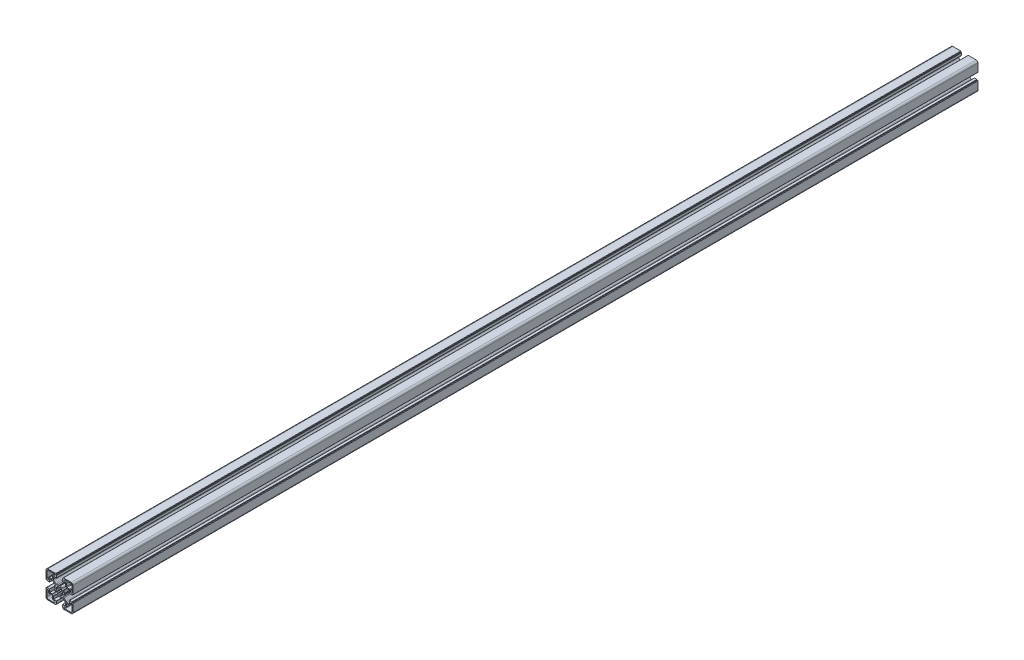
from build123d import *

# Parameters (mm, degrees)
BASE_EXTRUDE_DEPTH = 1510


with BuildPart() as part:
    # Sketch1 → Base-Extrude (new body)
    with BuildSketch(Plane.XY):
        with BuildLine():
            Line((7.973976585, 0.792591518), (7.540060475, 0.046829556))
            ThreePointArc((7.540060475, 0.046829556), (7.534295984, 0.023675638), (7.531329941, 0))
            ThreePointArc((7.531329941, 0), (7.534295984, -0.023675638), (7.540060475, -0.046829556))
            Line((7.540060475, -0.046829556), (7.973976585, -0.792591518))
            ThreePointArc((7.973976585, -0.792591518), (7.996666421, -0.851255641), (8.000014047, -0.914065683))
            ThreePointArc((8.000014047, -0.914065683), (7.719730741, -2.298395946), (7.20036345, -3.611859543))
            ThreePointArc((7.20036345, -3.611859543), (7.018857217, -4.793954471), (7.563483933, -5.85869607))
            Line((7.563483933, -5.85869607), (11.129779889, -9.424988026))
            ThreePointArc((11.129779889, -9.424988026), (11.760624613, -9.84650461), (12.504756513, -9.99452154))
            Line((12.504756513, -9.99452154), (16.316902451, -9.99452154))
            ThreePointArc((16.316902451, -9.99452154), (16.458324055, -9.935942793), (16.516902802, -9.794521189))
            Line((16.516902802, -9.794521189), (16.516902802, -5.200014226))
            ThreePointArc((16.516902802, -5.200014226), (16.575481548, -5.058592621), (16.716903152, -5.000013875))
            Line((16.716903152, -5.000013875), (20.719599904, -5.000013875))
            ThreePointArc((20.719599904, -5.000013875), (20.931731427, -5.087881629), (21.01959918, -5.300013151))
            Line((21.01959918, -5.300013151), (21.01959918, -5.500004099))
            ThreePointArc((21.01959918, -5.500004099), (21.10746708, -5.712135974), (21.319598956, -5.800003874))
            Line((21.319598956, -5.800003874), (21.999979514, -5.800003874))
            ThreePointArc((21.999979514, -5.800003874), (22.35353264, -5.946450374), (22.49997914, -6.300003501))
            Line((22.49997914, -6.300003501), (22.49997914, -19.500016116))
            ThreePointArc((22.49997914, -19.500016116), (21.62130014, -21.621334875), (19.499981381, -22.500013875))
            Line((19.499981381, -22.500013875), (6.375709012, -22.500013875))
            ThreePointArc((6.375709012, -22.500013875), (6.022155886, -22.353567375), (5.875709386, -22.000014249))
            Line((5.875709386, -22.000014249), (5.875709386, -21.30001315))
            ThreePointArc((5.875709386, -21.30001315), (5.787841632, -21.087881628), (5.57571011, -21.000013874))
            Line((5.57571011, -21.000013874), (5.299998776, -21.000013874))
            ThreePointArc((5.299998776, -21.000013874), (5.087867607, -20.912146267), (5, -20.700015099))
            Line((5, -20.700015099), (5, -16.666812433))
            ThreePointArc((5, -16.666812433), (5.058578893, -16.525390475), (5.200000851, -16.466811582))
            Line((5.200000851, -16.466811582), (9.905385218, -16.466811582))
            ThreePointArc((9.905385218, -16.466811582), (10.046806822, -16.408232835), (10.105385569, -16.266811231))
            Line((10.105385569, -16.266811231), (10.105385569, -12.471582956))
            ThreePointArc((10.105385569, -12.471582956), (9.953144588, -11.706215861), (9.519598955, -11.057368968))
            Line((9.519598955, -11.057368968), (5.944897989, -7.482668002))
            ThreePointArc((5.944897989, -7.482668002), (4.854601835, -6.967833724), (3.666499237, -7.173289937))
            ThreePointArc((3.666499237, -7.173289937), (2.309136684, -7.713848333), (0.876396038, -8.000013875))
            ThreePointArc((0.876396038, -8.000013875), (0.81356491, -7.997088573), (0.754749577, -7.974793627))
            Line((0.754749577, -7.974793627), (0.11262846, -7.606936933))
            ThreePointArc((0.11262846, -7.606936933), (0.062963903, -7.559088739), (0, -7.530953975))
            ThreePointArc((0, -7.530953975), (-0.062963903, -7.559088739), (-0.11262846, -7.606936933))
            Line((-0.11262846, -7.606936933), (-0.754749577, -7.974793627))
            ThreePointArc((-0.754749577, -7.974793627), (-0.81356491, -7.997088573), (-0.876396038, -8.000013875))
            ThreePointArc((-0.876396038, -8.000013875), (-2.309136684, -7.713848333), (-3.666499237, -7.173289937))
            ThreePointArc((-3.666499237, -7.173289937), (-4.854601835, -6.967833724), (-5.944897989, -7.482668002))
            Line((-5.944897989, -7.482668002), (-9.519598955, -11.057368968))
            ThreePointArc((-9.519598955, -11.057368968), (-9.953144588, -11.706215861), (-10.105385569, -12.471582956))
            Line((-10.105385569, -12.471582956), (-10.105385569, -16.266811231))
            ThreePointArc((-10.105385569, -16.266811231), (-10.046806822, -16.408232835), (-9.905385218, -16.466811582))
            Line((-9.905385218, -16.466811582), (-5.200000851, -16.466811582))
            ThreePointArc((-5.200000851, -16.466811582), (-5.058578893, -16.525390475), (-5, -16.666812433))
            Line((-5, -16.666812433), (-5, -20.700015099))
            ThreePointArc((-5, -20.700015099), (-5.087867607, -20.912146267), (-5.299998776, -21.000013874))
            Line((-5.299998776, -21.000013874), (-5.57571011, -21.000013874))
            ThreePointArc((-5.57571011, -21.000013874), (-5.787841632, -21.087881628), (-5.875709386, -21.30001315))
            Line((-5.875709386, -21.30001315), (-5.875709386, -22.000014249))
            ThreePointArc((-5.875709386, -22.000014249), (-6.022155886, -22.353567375), (-6.375709012, -22.500013875))
            Line((-6.375709012, -22.500013875), (-19.499981381, -22.500013875))
            ThreePointArc((-19.499981381, -22.500013875), (-21.62130014, -21.621334875), (-22.49997914, -19.500016116))
            Line((-22.49997914, -19.500016116), (-22.49997914, -6.300003501))
            ThreePointArc((-22.49997914, -6.300003501), (-22.35353264, -5.946450374), (-21.999979514, -5.800003874))
            Line((-21.999979514, -5.800003874), (-21.319598956, -5.800003874))
            ThreePointArc((-21.319598956, -5.800003874), (-21.10746708, -5.712135974), (-21.01959918, -5.500004099))
            Line((-21.01959918, -5.500004099), (-21.01959918, -5.300013151))
            ThreePointArc((-21.01959918, -5.300013151), (-20.931731427, -5.087881629), (-20.719599904, -5.000013875))
            Line((-20.719599904, -5.000013875), (-16.716903152, -5.000013875))
            ThreePointArc((-16.716903152, -5.000013875), (-16.575481548, -5.058592621), (-16.516902802, -5.200014226))
            Line((-16.516902802, -5.200014226), (-16.516902802, -9.794521189))
            ThreePointArc((-16.516902802, -9.794521189), (-16.458324055, -9.935942793), (-16.316902451, -9.99452154))
            Line((-16.316902451, -9.99452154), (-12.504756513, -9.99452154))
            ThreePointArc((-12.504756513, -9.99452154), (-11.760624613, -9.84650461), (-11.129779889, -9.424988026))
            Line((-11.129779889, -9.424988026), (-7.563483933, -5.85869607))
            ThreePointArc((-7.563483933, -5.85869607), (-7.018857217, -4.793954471), (-7.20036345, -3.611859543))
            ThreePointArc((-7.20036345, -3.611859543), (-7.719730741, -2.298395946), (-8.000014047, -0.914065683))
            ThreePointArc((-8.000014047, -0.914065683), (-7.996666421, -0.851255641), (-7.973976585, -0.792591518))
            Line((-7.973976585, -0.792591518), (-7.540060475, -0.046829556))
            ThreePointArc((-7.540060475, -0.046829556), (-7.534295984, -0.023675638), (-7.531329941, 0))
            ThreePointArc((-7.531329941, 0), (-7.534295984, 0.023675638), (-7.540060475, 0.046829556))
            Line((-7.540060475, 0.046829556), (-7.973976585, 0.792591518))
            ThreePointArc((-7.973976585, 0.792591518), (-7.996666421, 0.851255641), (-8.000014047, 0.914065683))
            ThreePointArc((-8.000014047, 0.914065683), (-7.719730741, 2.298395946), (-7.20036345, 3.611859543))
            ThreePointArc((-7.20036345, 3.611859543), (-7.018857217, 4.793954471), (-7.563483933, 5.85869607))
            Line((-7.563483933, 5.85869607), (-11.129779889, 9.424988026))
            ThreePointArc((-11.129779889, 9.424988026), (-11.760624613, 9.84650461), (-12.504756513, 9.99452154))
            Line((-12.504756513, 9.99452154), (-16.316902451, 9.99452154))
            ThreePointArc((-16.316902451, 9.99452154), (-16.458324055, 9.935942793), (-16.516902802, 9.794521189))
            Line((-16.516902802, 9.794521189), (-16.516902802, 5.200014226))
            ThreePointArc((-16.516902802, 5.200014226), (-16.575481548, 5.058592621), (-16.716903152, 5.000013875))
            Line((-16.716903152, 5.000013875), (-20.719599904, 5.000013875))
            ThreePointArc((-20.719599904, 5.000013875), (-20.931731427, 5.087881629), (-21.01959918, 5.300013151))
            Line((-21.01959918, 5.300013151), (-21.01959918, 5.500004099))
            ThreePointArc((-21.01959918, 5.500004099), (-21.10746708, 5.712135974), (-21.319598956, 5.800003874))
            Line((-21.319598956, 5.800003874), (-21.999979514, 5.800003874))
            ThreePointArc((-21.999979514, 5.800003874), (-22.35353264, 5.946450374), (-22.49997914, 6.300003501))
            Line((-22.49997914, 6.300003501), (-22.49997914, 19.500016116))
            ThreePointArc((-22.49997914, 19.500016116), (-21.62130014, 21.621334875), (-19.499981381, 22.500013875))
            Line((-19.499981381, 22.500013875), (-6.375709012, 22.500013875))
            ThreePointArc((-6.375709012, 22.500013875), (-6.022155886, 22.353567375), (-5.875709386, 22.000014249))
            Line((-5.875709386, 22.000014249), (-5.875709386, 21.30001315))
            ThreePointArc((-5.875709386, 21.30001315), (-5.787841632, 21.087881628), (-5.57571011, 21.000013874))
            Line((-5.57571011, 21.000013874), (-5.299998776, 21.000013874))
            ThreePointArc((-5.299998776, 21.000013874), (-5.087867607, 20.912146267), (-5, 20.700015099))
            Line((-5, 20.700015099), (-5, 16.666812433))
            ThreePointArc((-5, 16.666812433), (-5.058578893, 16.525390475), (-5.200000851, 16.466811582))
            Line((-5.200000851, 16.466811582), (-9.905385218, 16.466811582))
            ThreePointArc((-9.905385218, 16.466811582), (-10.046806822, 16.408232835), (-10.105385569, 16.266811231))
            Line((-10.105385569, 16.266811231), (-10.105385569, 12.471582956))
            ThreePointArc((-10.105385569, 12.471582956), (-9.953144588, 11.706215861), (-9.519598955, 11.057368968))
            Line((-9.519598955, 11.057368968), (-5.944897989, 7.482668002))
            ThreePointArc((-5.944897989, 7.482668002), (-4.854601835, 6.967833724), (-3.666499237, 7.173289937))
            ThreePointArc((-3.666499237, 7.173289937), (-2.309136684, 7.713848333), (-0.876396038, 8.000013875))
            ThreePointArc((-0.876396038, 8.000013875), (-0.81356491, 7.997088573), (-0.754749577, 7.974793627))
            Line((-0.754749577, 7.974793627), (-0.11262846, 7.606936933))
            ThreePointArc((-0.11262846, 7.606936933), (-0.062963903, 7.559088739), (0, 7.530953975))
            ThreePointArc((0, 7.530953975), (0.062963903, 7.559088739), (0.11262846, 7.606936933))
            Line((0.11262846, 7.606936933), (0.754749577, 7.974793627))
            ThreePointArc((0.754749577, 7.974793627), (0.81356491, 7.997088573), (0.876396038, 8.000013875))
            ThreePointArc((0.876396038, 8.000013875), (2.309136684, 7.713848333), (3.666499237, 7.173289937))
            ThreePointArc((3.666499237, 7.173289937), (4.854601835, 6.967833724), (5.944897989, 7.482668002))
            Line((5.944897989, 7.482668002), (9.519598955, 11.057368968))
            ThreePointArc((9.519598955, 11.057368968), (9.953144588, 11.706215861), (10.105385569, 12.471582956))
            Line((10.105385569, 12.471582956), (10.105385569, 16.266811231))
            ThreePointArc((10.105385569, 16.266811231), (10.046806822, 16.408232835), (9.905385218, 16.466811582))
            Line((9.905385218, 16.466811582), (5.200000851, 16.466811582))
            ThreePointArc((5.200000851, 16.466811582), (5.058578893, 16.525390475), (5, 16.666812433))
            Line((5, 16.666812433), (5, 20.700015099))
            ThreePointArc((5, 20.700015099), (5.087867607, 20.912146267), (5.299998776, 21.000013874))
            Line((5.299998776, 21.000013874), (5.57571011, 21.000013874))
            ThreePointArc((5.57571011, 21.000013874), (5.787841632, 21.087881628), (5.875709386, 21.30001315))
            Line((5.875709386, 21.30001315), (5.875709386, 22.000014249))
            ThreePointArc((5.875709386, 22.000014249), (6.022155886, 22.353567375), (6.375709012, 22.500013875))
            Line((6.375709012, 22.500013875), (19.499981381, 22.500013875))
            ThreePointArc((19.499981381, 22.500013875), (21.62130014, 21.621334875), (22.49997914, 19.500016116))
            Line((22.49997914, 19.500016116), (22.49997914, 6.300003501))
            ThreePointArc((22.49997914, 6.300003501), (22.35353264, 5.946450374), (21.999979514, 5.800003874))
            Line((21.999979514, 5.800003874), (21.319598956, 5.800003874))
            ThreePointArc((21.319598956, 5.800003874), (21.10746708, 5.712135974), (21.01959918, 5.500004099))
            Line((21.01959918, 5.500004099), (21.01959918, 5.300013151))
            ThreePointArc((21.01959918, 5.300013151), (20.931731427, 5.087881629), (20.719599904, 5.000013875))
            Line((20.719599904, 5.000013875), (16.716903152, 5.000013875))
            ThreePointArc((16.716903152, 5.000013875), (16.575481548, 5.058592621), (16.516902802, 5.200014226))
            Line((16.516902802, 5.200014226), (16.516902802, 9.794521189))
            ThreePointArc((16.516902802, 9.794521189), (16.458324055, 9.935942793), (16.316902451, 9.99452154))
            Line((16.316902451, 9.99452154), (12.504756513, 9.99452154))
            ThreePointArc((12.504756513, 9.99452154), (11.760624613, 9.84650461), (11.129779889, 9.424988026))
            Line((11.129779889, 9.424988026), (7.563483933, 5.85869607))
            ThreePointArc((7.563483933, 5.85869607), (7.018857217, 4.793954471), (7.20036345, 3.611859543))
            ThreePointArc((7.20036345, 3.611859543), (7.719730741, 2.298395946), (8.000014047, 0.914065683))
            ThreePointArc((8.000014047, 0.914065683), (7.996666421, 0.851255641), (7.973976585, 0.792591518))
        make_face()
        with BuildLine():
            Line((10.549978885, 18.000013874), (8.999979138, 18.000013874))
            ThreePointArc((8.999979138, 18.000013874), (7.499979138, 19.500013874), (8.999979138, 21.000013874))
            Line((8.999979138, 21.000013874), (18.499981006, 21.000013874))
            ThreePointArc((18.499981006, 21.000013874), (20.267746638, 20.267781374), (20.999979138, 18.500015742))
            Line((20.999979138, 18.500015742), (20.999979138, 9.000204874))
            ThreePointArc((20.999979138, 9.000204874), (19.499979138, 7.500204874), (17.999979138, 9.000204874))
            Line((17.999979138, 9.000204874), (17.999979138, 10.550013621))
            ThreePointArc((17.999979138, 10.550013621), (17.707086138, 11.257119874), (16.999979885, 11.550012874))
            Line((16.999979885, 11.550012874), (12.549977391, 11.550012874))
            ThreePointArc((12.549977391, 11.550012874), (11.842871138, 11.842905874), (11.549978138, 12.550012127))
            Line((11.549978138, 12.550012127), (11.549978138, 17.000014621))
            ThreePointArc((11.549978138, 17.000014621), (11.257085138, 17.707120874), (10.549978885, 18.000013874))
        make_face(mode=Mode.SUBTRACT)
        with BuildLine():
            Line((-0.867388737, 4.924188946), (-0.96752168, 5.481112935))
            ThreePointArc((-0.96752168, 5.481112935), (-1.187855719, 5.829589164), (-1.595071417, 5.894072848))
            ThreePointArc((-1.595071417, 5.894072848), (-2.338895973, 5.643477696), (-3.04438497, 5.299445466))
            ThreePointArc((-3.04438497, 5.299445466), (-3.284615367, 4.964275075), (-3.191311906, 4.562598216))
            Line((-3.191311906, 4.562598216), (-2.864000421, 4.09847552))
            ThreePointArc((-2.864000421, 4.09847552), (-3.53013295, 3.540926624), (-4.08971289, 2.876499344))
            Line((-4.08971289, 2.876499344), (-4.566777651, 3.208162503))
            ThreePointArc((-4.566777651, 3.208162503), (-4.968960845, 3.298770682), (-5.302497889, 3.056460542))
            ThreePointArc((-5.302497889, 3.056460542), (-5.651259984, 2.353310881), (-5.906847665, 1.611199444))
            ThreePointArc((-5.906847665, 1.611199444), (-5.839752063, 1.204293023), (-5.489730697, 0.98621116))
            Line((-5.489730697, 0.98621116), (-4.920545766, 0.887822825))
            ThreePointArc((-4.920545766, 0.887822825), (-4.980096828, 0.445685524), (-5, 0))
            ThreePointArc((-5, 0), (-4.980096828, -0.445685524), (-4.920545766, -0.887822825))
            Line((-4.920545766, -0.887822825), (-5.489730697, -0.98621116))
            ThreePointArc((-5.489730697, -0.98621116), (-5.839752063, -1.204293023), (-5.906847665, -1.611199444))
            ThreePointArc((-5.906847665, -1.611199444), (-5.651259984, -2.353310881), (-5.302497889, -3.056460542))
            ThreePointArc((-5.302497889, -3.056460542), (-4.968960845, -3.298770682), (-4.566777651, -3.208162503))
            Line((-4.566777651, -3.208162503), (-4.08971289, -2.876499344))
            ThreePointArc((-4.08971289, -2.876499344), (-3.53013295, -3.540926624), (-2.864000421, -4.09847552))
            Line((-2.864000421, -4.09847552), (-3.191311906, -4.562598216))
            ThreePointArc((-3.191311906, -4.562598216), (-3.284615367, -4.964275075), (-3.04438497, -5.299445466))
            ThreePointArc((-3.04438497, -5.299445466), (-2.338895973, -5.643477696), (-1.595071417, -5.894072848))
            ThreePointArc((-1.595071417, -5.894072848), (-1.187855719, -5.829589164), (-0.96752168, -5.481112935))
            Line((-0.96752168, -5.481112935), (-0.867388737, -4.924188946))
            ThreePointArc((-0.867388737, -4.924188946), (0, -5), (0.867388737, -4.924188946))
            Line((0.867388737, -4.924188946), (0.96752168, -5.481112935))
            ThreePointArc((0.96752168, -5.481112935), (1.187855719, -5.829589164), (1.595071417, -5.894072848))
            ThreePointArc((1.595071417, -5.894072848), (2.338895973, -5.643477696), (3.04438497, -5.299445466))
            ThreePointArc((3.04438497, -5.299445466), (3.284615367, -4.964275075), (3.191311906, -4.562598216))
            Line((3.191311906, -4.562598216), (2.864000421, -4.09847552))
            ThreePointArc((2.864000421, -4.09847552), (3.53013295, -3.540926624), (4.08971289, -2.876499344))
            Line((4.08971289, -2.876499344), (4.566777651, -3.208162503))
            ThreePointArc((4.566777651, -3.208162503), (4.968960845, -3.298770682), (5.302497889, -3.056460542))
            ThreePointArc((5.302497889, -3.056460542), (5.651259984, -2.353310881), (5.906847665, -1.611199444))
            ThreePointArc((5.906847665, -1.611199444), (5.839752063, -1.204293023), (5.489730697, -0.98621116))
            Line((5.489730697, -0.98621116), (4.920545766, -0.887822825))
            ThreePointArc((4.920545766, -0.887822825), (4.980096828, -0.445685524), (5, 0))
            ThreePointArc((5, 0), (4.980096828, 0.445685524), (4.920545766, 0.887822825))
            Line((4.920545766, 0.887822825), (5.489730697, 0.98621116))
            ThreePointArc((5.489730697, 0.98621116), (5.839752063, 1.204293023), (5.906847665, 1.611199444))
            ThreePointArc((5.906847665, 1.611199444), (5.651259984, 2.353310881), (5.302497889, 3.056460542))
            ThreePointArc((5.302497889, 3.056460542), (4.968960845, 3.298770682), (4.566777651, 3.208162503))
            Line((4.566777651, 3.208162503), (4.08971289, 2.876499344))
            ThreePointArc((4.08971289, 2.876499344), (3.53013295, 3.540926624), (2.864000421, 4.09847552))
            Line((2.864000421, 4.09847552), (3.191311906, 4.562598216))
            ThreePointArc((3.191311906, 4.562598216), (3.284615367, 4.964275075), (3.04438497, 5.299445466))
            ThreePointArc((3.04438497, 5.299445466), (2.338895973, 5.643477696), (1.595071417, 5.894072848))
            ThreePointArc((1.595071417, 5.894072848), (1.187855719, 5.829589164), (0.96752168, 5.481112935))
            Line((0.96752168, 5.481112935), (0.867388737, 4.924188946))
            ThreePointArc((0.867388737, 4.924188946), (0, 5), (-0.867388737, 4.924188946))
        make_face(mode=Mode.SUBTRACT)
        with BuildLine():
            Line((-10.549978885, -18.000013874), (-8.999979138, -18.000013874))
            ThreePointArc((-8.999979138, -18.000013874), (-7.499979138, -19.500013874), (-8.999979138, -21.000013874))
            Line((-8.999979138, -21.000013874), (-18.499981006, -21.000013874))
            ThreePointArc((-18.499981006, -21.000013874), (-20.267746638, -20.267781374), (-20.999979138, -18.500015742))
            Line((-20.999979138, -18.500015742), (-20.999979138, -9.000204874))
            ThreePointArc((-20.999979138, -9.000204874), (-19.499979138, -7.500204874), (-17.999979138, -9.000204874))
            Line((-17.999979138, -9.000204874), (-17.999979138, -10.550013621))
            ThreePointArc((-17.999979138, -10.550013621), (-17.707086138, -11.257119874), (-16.999979885, -11.550012874))
            Line((-16.999979885, -11.550012874), (-12.549977391, -11.550012874))
            ThreePointArc((-12.549977391, -11.550012874), (-11.842871138, -11.842905874), (-11.549978138, -12.550012127))
            Line((-11.549978138, -12.550012127), (-11.549978138, -17.000014621))
            ThreePointArc((-11.549978138, -17.000014621), (-11.257085138, -17.707120874), (-10.549978885, -18.000013874))
        make_face(mode=Mode.SUBTRACT)
        with BuildLine():
            Line((-11.549978138, 12.550012127), (-11.549978138, 17.000014621))
            ThreePointArc((-11.549978138, 17.000014621), (-11.257085138, 17.707120874), (-10.549978885, 18.000013874))
            Line((-10.549978885, 18.000013874), (-8.999979138, 18.000013874))
            ThreePointArc((-8.999979138, 18.000013874), (-7.499979138, 19.500013874), (-8.999979138, 21.000013874))
            Line((-8.999979138, 21.000013874), (-18.499981006, 21.000013874))
            ThreePointArc((-18.499981006, 21.000013874), (-20.267746638, 20.267781374), (-20.999979138, 18.500015742))
            Line((-20.999979138, 18.500015742), (-20.999979138, 9.000204874))
            ThreePointArc((-20.999979138, 9.000204874), (-19.499979138, 7.500204874), (-17.999979138, 9.000204874))
            Line((-17.999979138, 9.000204874), (-17.999979138, 10.550013621))
            ThreePointArc((-17.999979138, 10.550013621), (-17.707086138, 11.257119874), (-16.999979885, 11.550012874))
            Line((-16.999979885, 11.550012874), (-12.549977391, 11.550012874))
            ThreePointArc((-12.549977391, 11.550012874), (-11.842871138, 11.842905874), (-11.549978138, 12.550012127))
        make_face(mode=Mode.SUBTRACT)
        with BuildLine():
            Line((11.549978138, -12.550012127), (11.549978138, -17.000014621))
            ThreePointArc((11.549978138, -17.000014621), (11.257085138, -17.707120874), (10.549978885, -18.000013874))
            Line((10.549978885, -18.000013874), (8.999979138, -18.000013874))
            ThreePointArc((8.999979138, -18.000013874), (7.499979138, -19.500013874), (8.999979138, -21.000013874))
            Line((8.999979138, -21.000013874), (18.499981006, -21.000013874))
            ThreePointArc((18.499981006, -21.000013874), (20.267746638, -20.267781374), (20.999979138, -18.500015742))
            Line((20.999979138, -18.500015742), (20.999979138, -9.000204874))
            ThreePointArc((20.999979138, -9.000204874), (19.499979138, -7.500204874), (17.999979138, -9.000204874))
            Line((17.999979138, -9.000204874), (17.999979138, -10.550013621))
            ThreePointArc((17.999979138, -10.550013621), (17.707086138, -11.257119874), (16.999979885, -11.550012874))
            Line((16.999979885, -11.550012874), (12.549977391, -11.550012874))
            ThreePointArc((12.549977391, -11.550012874), (11.842871138, -11.842905874), (11.549978138, -12.550012127))
        make_face(mode=Mode.SUBTRACT)
    extrude(amount=-BASE_EXTRUDE_DEPTH)


solid = part.part
